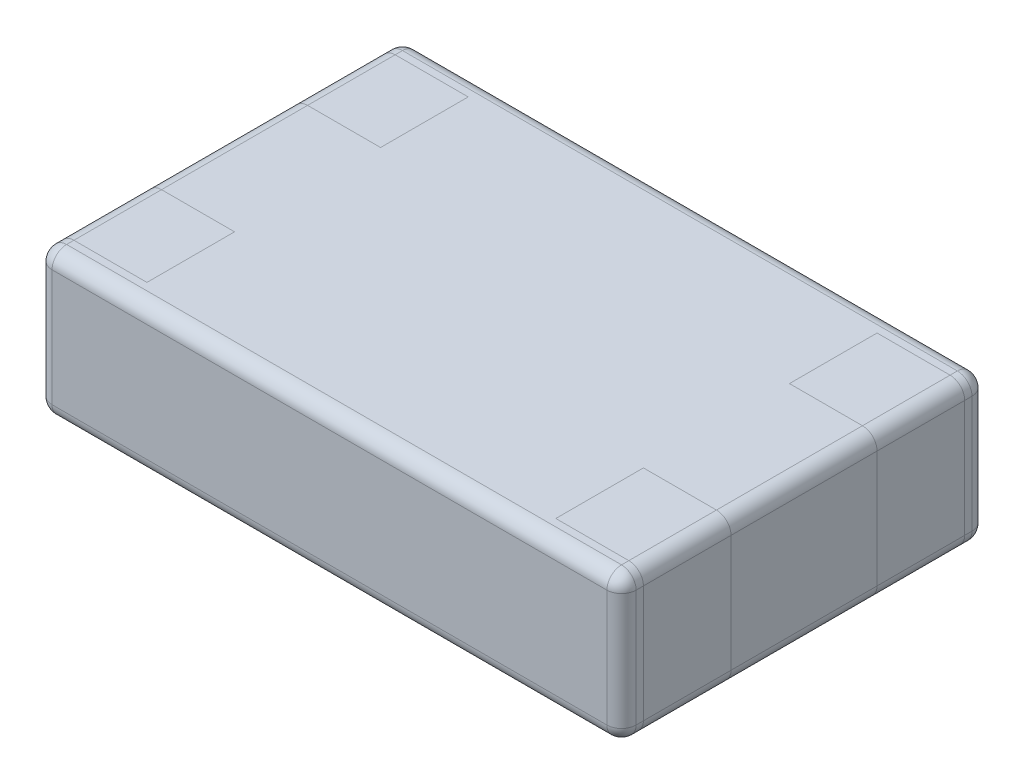
from build123d import *

# Parameters (mm, degrees)
SKETCH1_W           = 2
SKETCH1_H           = 1.25
BOSS_EXTRUDE1_DEPTH = 0.5
FILLET1_R           = 0.05


with BuildPart() as part:
    # Sketch1 → Boss-Extrude1 (new body)
    with BuildSketch(Plane(origin=(0, 0, 0), x_dir=(1, 0, 0), z_dir=(0, 1, 0))):
        Rectangle(SKETCH1_W, SKETCH1_H)
    extrude(amount=BOSS_EXTRUDE1_DEPTH)

    # Fillet1
    fillet1_edges = [part.edges().sort_by_distance(p)[0] for p in [
        (1, 0.5, 0),
        (0, 0.5, -0.625),
        (1, 0, 0),
        (1, 0, 0),
        (1, 0.5, 0),
        (1, 0.5, 0),
        (1, 0, 0),
        (1, 0, 0),
        (1, 0.5, 0),
        (1, 0.5, 0),
        (-1, 0, 0),
        (-1, 0, 0),
        (-1, 0.5, 0),
        (-1, 0.5, 0),
        (-1, 0.5, 0),
        (-1, 0.5, 0),
        (-1, 0, 0),
        (-1, 0, 0),
        (-1, 0.5, 0),
        (0, 0, -0.625),
        (1, 0, 0),
        (0, 0, 0.625),
        (-1, 0, 0),
        (0, 0.5, 0.625),
        (-1, 0.25, -0.625),
        (1, 0.25, -0.625),
        (1, 0.25, 0.625),
        (-1, 0.25, 0.625),
    ]]
    fillet(fillet1_edges, radius=FILLET1_R)


solid = part.part
